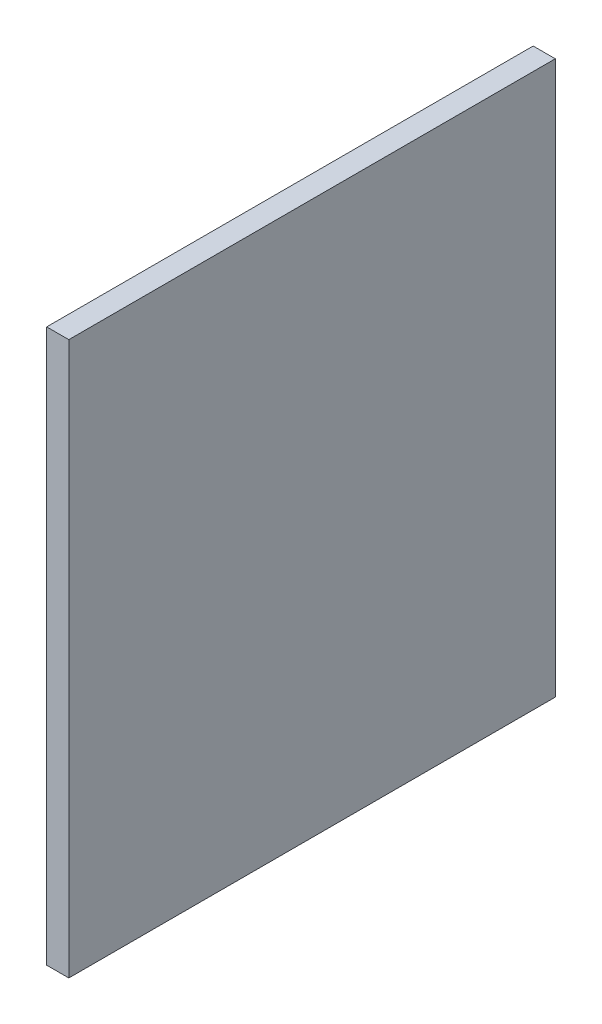
from build123d import *

# Parameters (mm, degrees)
ESQUISSE1_W        = 440
ESQUISSE1_H        = 500
BOSS_EXTRU_1_DEPTH = 20


with BuildPart() as part:
    # Esquisse1 → Boss.-Extru.1 (new body)
    with BuildSketch(Plane(origin=(0, 0, 0), x_dir=(0, 0, -1), z_dir=(1, 0, 0))):
        Rectangle(ESQUISSE1_W, ESQUISSE1_H)
    extrude(amount=BOSS_EXTRU_1_DEPTH)


solid = part.part
